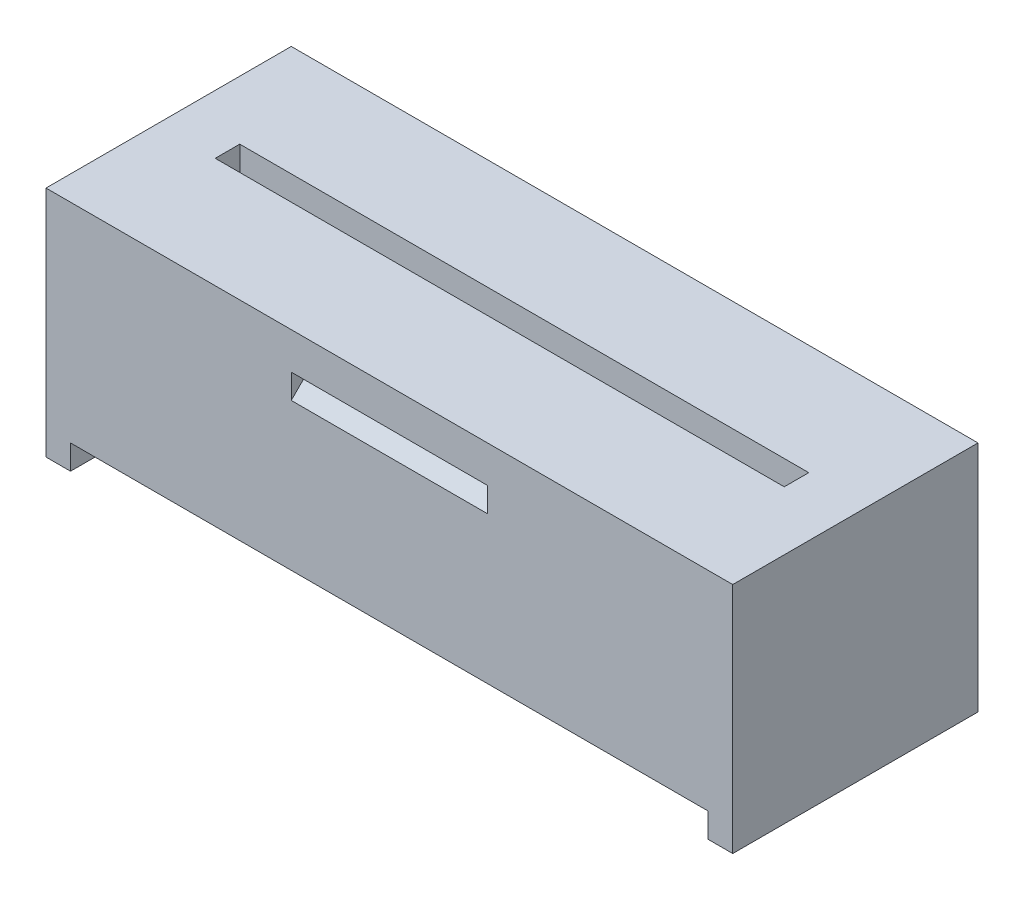
from build123d import *

# Parameters (mm, degrees)
SKICA1_W                 = 28
SKICA1_H                 = 8.5
P_IDAT_VYSUNUT_M1_DEPTH  = 10
SKICA3_R                 = 2.6
ODEBRAT_VYSUNUT_M2_DEPTH = 7.5
SKICA4_W                 = 23.2
SKICA4_H                 = 1
ODEBRAT_VYSUNUT_M3_DEPTH = 1
SKICA5_W                 = 1
SKICA5_H                 = 10
P_IDAT_VYSUNUT_M2_DEPTH  = 1
ODEBRAT_START            = -10
ODEBRAT_VYSUNUT_M5_DEPTH = 8


with BuildPart() as part:
    # Skica1 → Přidat vysunutím1 (new body)
    with BuildSketch(Plane.XY):
        with Locations((-32.656744291, -2.464704976)):
            Rectangle(SKICA1_W, SKICA1_H)
    extrude(amount=P_IDAT_VYSUNUT_M1_DEPTH)

    # Skica3 → Odebrat vysunutím2 (cut)
    with BuildSketch(Plane(origin=(0, -6.714704976, 0), x_dir=(-1, 0, 0), z_dir=(0, -1, 0))):
        with Locations((41.656744291, -5)):
            Circle(SKICA3_R)
        with Locations((35.646744291, -5)):
            Circle(SKICA3_R)
        with Locations((29.636744291, -5)):
            Circle(SKICA3_R)
        with Locations((23.626744291, -5)):
            Circle(SKICA3_R)
    extrude(amount=-ODEBRAT_VYSUNUT_M2_DEPTH, mode=Mode.SUBTRACT)

    # Skica4 → Odebrat vysunutím3 (cut)
    with BuildSketch(Plane(origin=(0, 1.785295024, 0), x_dir=(1, 0, 0), z_dir=(0, 1, 0))):
        with Locations((-32.656744291, -5)):
            Rectangle(SKICA4_W, SKICA4_H)
    extrude(amount=-ODEBRAT_VYSUNUT_M3_DEPTH, mode=Mode.SUBTRACT)

    # Skica5 → Přidat vysunutím2 (add)
    with BuildSketch(Plane(origin=(0, -6.714704976, 0), x_dir=(-1, 0, 0), z_dir=(0, -1, 0))):
        with Locations((46.156744291, -5)):
            Rectangle(SKICA5_W, SKICA5_H)
        with Locations((19.156744291, -5)):
            Rectangle(SKICA5_W, SKICA5_H)
    extrude(amount=P_IDAT_VYSUNUT_M2_DEPTH)

    # Skica9 → Odebrat vysunutím5 (cut)
    with BuildSketch(Plane(origin=(-18.656744291, 0, 0), x_dir=(0, 0, -1), z_dir=(1, 0, 0)).offset(ODEBRAT_START)):
        Polygon((-10, 0.285295024), (-9, 0.285295024), (-10, -0.714704976), align=None)
        Polygon((0, 0.285295024), (-1, 0.285295024), (0, -0.714704976), align=None)
    extrude(amount=-ODEBRAT_VYSUNUT_M5_DEPTH, mode=Mode.SUBTRACT)


solid = part.part
